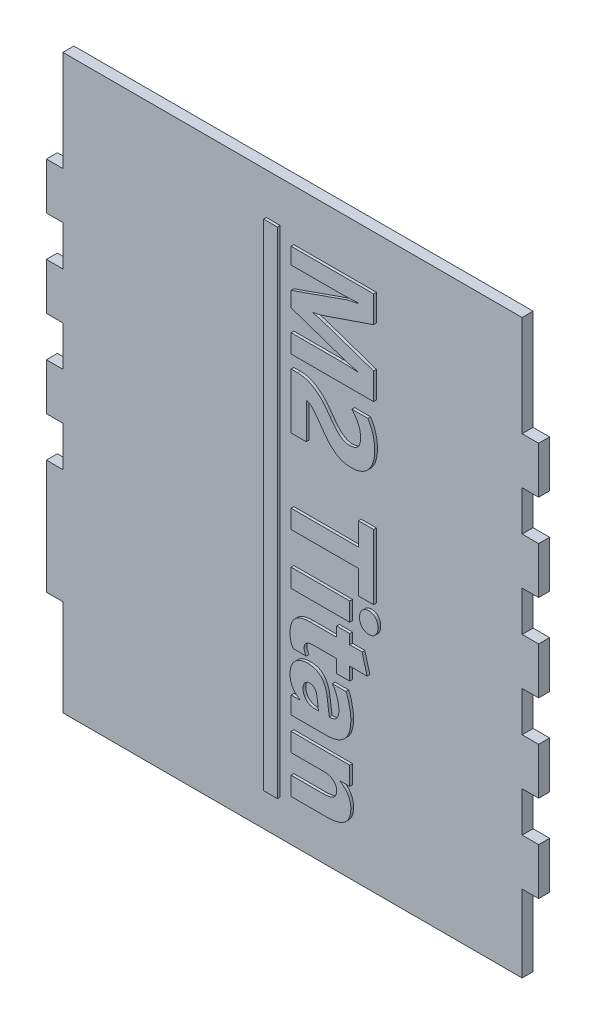
from build123d import *

# Parameters (mm, degrees)
SKETCH1_W           = 113.665
SKETCH1_H           = 132.08
BOSS_EXTRUDE1_DEPTH = 2.54
SKETCH2_W           = 3.81
SKETCH2_H           = 22.225
SKETCH2_H_2         = 23.241
SKETCH2_H_3         = 9.271
SKETCH2_H_4         = 17.78
CUT_EXTRUDE1_DEPTH  = 3.81
SKETCH5_W           = 3.175
SKETCH5_H           = 114.3
SKETCH5_W_2         = 13.535526316
SKETCH5_H_2         = 4.261184211
BOSS_EXTRUDE2_DEPTH = 0.635


with BuildPart() as part:
    # Sketch1 → Boss-Extrude1 (new body)
    with BuildSketch(Plane.XY):
        with Locations((56.8325, 66.04)):
            Rectangle(SKETCH1_W, SKETCH1_H)
    extrude(amount=BOSS_EXTRUDE1_DEPTH)

    # Sketch2 → Cut-Extrude1 (cut)
    with BuildSketch(Plane.XY.offset(2.54)):
        with Locations((1.905, 11.1125)):
            Rectangle(SKETCH2_W, SKETCH2_H)
        with Locations((1.905, 120.4595)):
            Rectangle(SKETCH2_W, SKETCH2_H_2)
        with Locations((1.905, 93.4085)):
            Rectangle(SKETCH2_W, SKETCH2_H_3)
        with Locations((1.905, 73.3425)):
            Rectangle(SKETCH2_W, SKETCH2_H_3)
        with Locations((1.905, 53.2765)):
            Rectangle(SKETCH2_W, SKETCH2_H_3)
        with Locations((111.76, 120.4595)):
            Rectangle(SKETCH2_W, SKETCH2_H_2)
        with Locations((111.76, 93.4085)):
            Rectangle(SKETCH2_W, SKETCH2_H_3)
        with Locations((111.76, 73.3425)):
            Rectangle(SKETCH2_W, SKETCH2_H_3)
        with Locations((111.76, 53.2765)):
            Rectangle(SKETCH2_W, SKETCH2_H_3)
        with Locations((111.76, 33.2105)):
            Rectangle(SKETCH2_W, SKETCH2_H_3)
        with Locations((111.76, 8.89)):
            Rectangle(SKETCH2_W, SKETCH2_H_4)
    extrude(amount=-CUT_EXTRUDE1_DEPTH, mode=Mode.SUBTRACT)

    # Sketch5 → Boss-Extrude2 (add)
    with BuildSketch(Plane.XY.offset(2.54)):
        with Locations((52.3875, 65.405)):
            Rectangle(SKETCH5_W, SKETCH5_H)
        with BuildLine():
            Line((57.15, 98.7425), (57.15, 103.003684211))
            Line((57.15, 103.003684211), (68.547101151, 103.003684211))
            add(Edge.make_bspline(
                [(68.547101151, 103.003684211), (68.863046339, 103.000629878), (69.5120088, 102.994356171), (70.508408278, 102.967962125), (71.552893128, 102.915680805), (72.26395596, 102.867686605), (72.628125, 102.843106497)],
                knots=[0, 0, 0, 0, 0.000947873, 0.001946964, 0.002990005, 0.004084988, 0.004084988, 0.004084988, 0.004084988], degree=3))
            Line((72.628125, 102.843106497), (72.628125, 102.948852796))
            add(Edge.make_bspline(
                [(72.628125, 102.948852796), (72.487117541, 102.976198315), (72.21540985, 103.028890475), (71.821986347, 103.106358345), (71.460684469, 103.18500854), (71.128571044, 103.258679244), (70.828787227, 103.333904656), (70.557686106, 103.402704312), (70.319131092, 103.473548316), (70.17106646, 103.521694876), (70.101963405, 103.544165296)],
                knots=[0, 0, 0, 0, 0.000430907, 0.000830316, 0.001202881, 0.001540181, 0.001850799, 0.002130083, 0.002379176, 0.002597168, 0.002597168, 0.002597168, 0.002597168], degree=3))
            Line((70.101963405, 103.544165296), (57.15, 107.985509868))
            Line((57.15, 107.985509868), (57.15, 111.475137747))
            Line((57.15, 111.475137747), (69.968801398, 115.994812911))
            add(Edge.make_bspline(
                [(69.968801398, 115.994812911), (70.019504819, 116.012485416), (70.137819051, 116.053723441), (70.344560255, 116.104300114), (70.601845366, 116.167536572), (70.907392822, 116.243813834), (71.266852338, 116.314240018), (71.674633282, 116.403054004), (72.13411484, 116.496211169), (72.458339275, 116.557848144), (72.628125, 116.590125411)],
                knots=[0, 0, 0, 0, 0.000161007, 0.000375703, 0.000637876, 0.000956105, 0.001320195, 0.001736528, 0.00220814, 0.002726618, 0.002726618, 0.002726618, 0.002726618], degree=3))
            Line((72.628125, 116.590125411), (72.628125, 116.707621299))
            add(Edge.make_bspline(
                [(72.628125, 116.707621299), (72.172575491, 116.681315442), (71.291789859, 116.630454185), (70.012144461, 116.581065874), (68.820129558, 116.547491312), (68.053638679, 116.541897461), (67.685464638, 116.539210526)],
                knots=[0, 0, 0, 0, 0.001368893, 0.002646696, 0.003841649, 0.004946173, 0.004946173, 0.004946173, 0.004946173], degree=3))
            Line((67.685464638, 116.539210526), (57.15, 116.539210526))
            Line((57.15, 116.539210526), (57.15, 120.299078947))
            Line((57.15, 120.299078947), (76.2, 120.299078947))
            Line((76.2, 120.299078947), (76.2, 114.134461349))
            Line((76.2, 114.134461349), (64.908645148, 110.261013569))
            add(Edge.make_bspline(
                [(64.908645148, 110.261013569), (64.683442113, 110.187053898), (64.234644325, 110.039662736), (63.553067513, 109.857982107), (62.871413996, 109.702674812), (62.414232426, 109.625691265), (62.186657072, 109.587370477)],
                knots=[0, 0, 0, 0, 0.000710977, 0.001416876, 0.002115261, 0.002807468, 0.002807468, 0.002807468, 0.002807468], degree=3))
            Line((62.186657072, 109.587370477), (62.186657072, 109.509039885))
            add(Edge.make_bspline(
                [(62.186657072, 109.509039885), (62.441483523, 109.450036023), (62.935388553, 109.335674644), (63.648968748, 109.152304128), (64.311084034, 108.961245176), (64.732758639, 108.823484725), (64.936060855, 108.757066201)],
                knots=[0, 0, 0, 0, 0.000784685, 0.001520878, 0.002210032, 0.002851626, 0.002851626, 0.002851626, 0.002851626], degree=3))
            Line((64.936060855, 108.757066201), (76.2, 104.883618421))
            Line((76.2, 104.883618421), (76.2, 98.7425))
            Line((76.2, 98.7425), (57.15, 98.7425))
        make_face()
        with BuildLine():
            Line((60.659210526, 91.222763158), (60.659210526, 82.951052632))
            Line((60.659210526, 82.951052632), (57.15, 82.951052632))
            Line((57.15, 82.951052632), (57.15, 95.734605263))
            Line((57.15, 95.734605263), (58.626531661, 95.734605263))
            add(Edge.make_bspline(
                [(58.626531661, 95.734605263), (58.861892718, 95.729064478), (59.321522061, 95.718244048), (59.99132946, 95.619819095), (60.627215256, 95.471158506), (61.222849985, 95.247935722), (61.781855966, 94.976879289), (62.317755731, 94.685968648), (62.819673151, 94.355723464), (63.289466648, 93.992402029), (63.735712991, 93.609775333), (64.155411445, 93.205675263), (64.547503775, 92.783062558), (65.021577135, 92.204147604), (65.569046885, 91.493069928), (65.979492703, 90.917168161), (66.17760074, 90.639200247)],
                knots=[0, 0, 0, 0, 0.000705671, 0.001378084, 0.002026881, 0.002661311, 0.003281472, 0.003889746, 0.004489371, 0.005081584, 0.005670367, 0.006252048, 0.00682851, 0.007398671, 0.008496173, 0.009520127, 0.009520127, 0.009520127, 0.009520127], degree=3))
            add(Edge.make_bspline(
                [(66.17760074, 90.639200247), (66.370124281, 90.372731172), (66.735064922, 89.86762206), (67.287113002, 89.168444547), (67.833665454, 88.578626313), (68.367322945, 88.079640608), (68.911594256, 87.693583523), (69.467478997, 87.411812645), (70.051761037, 87.243777965), (70.452081509, 87.222818694), (70.654194079, 87.212236842)],
                knots=[0, 0, 0, 0, 0.000986235, 0.001869471, 0.002670408, 0.003396753, 0.004057394, 0.004665176, 0.005259108, 0.005864741, 0.005864741, 0.005864741, 0.005864741], degree=3))
            add(Edge.make_bspline(
                [(70.654194079, 87.212236842), (70.852120603, 87.21942241), (71.226654642, 87.233019575), (71.750910931, 87.362899937), (72.198721721, 87.579804521), (72.505895062, 87.837974571), (72.703661213, 88.086009256), (72.838507344, 88.292956245), (72.947201076, 88.527147566), (73.036668494, 88.781830632), (73.107571489, 89.059585893), (73.158230215, 89.35947813), (73.183742641, 89.683132443), (73.189255662, 89.905467033), (73.192105263, 90.020388569)],
                knots=[0, 0, 0, 0, 0.000592963, 0.001122057, 0.001607233, 0.002074105, 0.002310821, 0.002557438, 0.002813214, 0.003083256, 0.003366332, 0.003672173, 0.003994496, 0.004339351, 0.004339351, 0.004339351, 0.004339351], degree=3))
            add(Edge.make_bspline(
                [(73.192105263, 90.020388569), (73.186054733, 90.224404484), (73.173928802, 90.633274903), (73.075994693, 91.242228233), (72.919225176, 91.844490506), (72.696921681, 92.439273248), (72.414104573, 93.028024111), (72.066589959, 93.608749049), (71.659021622, 94.183438752), (71.346562033, 94.546425696), (71.186842105, 94.731973684)],
                knots=[0, 0, 0, 0, 0.000611781, 0.001226078, 0.001845447, 0.002476203, 0.003127855, 0.003802226, 0.00450428, 0.005238418, 0.005238418, 0.005238418, 0.005238418], degree=3))
            Line((71.186842105, 94.731973684), (74.852713816, 94.731973684))
            add(Edge.make_bspline(
                [(74.852713816, 94.731973684), (74.981389983, 94.523683843), (75.237468921, 94.109165426), (75.56091837, 93.455622809), (75.837908598, 92.783540233), (76.058525966, 92.089642545), (76.237906742, 91.377343698), (76.361021605, 90.645260993), (76.438592194, 89.892831077), (76.446600665, 89.384798083), (76.450657895, 89.127419819)],
                knots=[0, 0, 0, 0, 0.000734148, 0.001461031, 0.002184699, 0.002912984, 0.003643457, 0.004386494, 0.005138243, 0.005910157, 0.005910157, 0.005910157, 0.005910157], degree=3))
            add(Edge.make_bspline(
                [(76.450657895, 89.127419819), (76.446229739, 88.89226763), (76.437573943, 88.432611317), (76.367680036, 87.761575045), (76.245333823, 87.129491885), (76.081664964, 86.535634315), (75.874860641, 85.981704783), (75.624718253, 85.470925998), (75.331424704, 85.005161301), (75.005082706, 84.57980529), (74.6315553, 84.205438786), (74.224918277, 83.87437183), (73.776095523, 83.595041867), (73.29504365, 83.359897958), (72.779251185, 83.174233849), (72.232249026, 83.047537199), (71.656623363, 82.966555668), (71.262841491, 82.956297375), (71.061513158, 82.951052632)],
                knots=[0, 0, 0, 0, 0.000705367, 0.001378794, 0.002020937, 0.002634784, 0.003224738, 0.003792243, 0.004337753, 0.004873617, 0.005397041, 0.005920627, 0.006443304, 0.006979297, 0.007524384, 0.008083914, 0.008661067, 0.009264836, 0.009264836, 0.009264836, 0.009264836], degree=3))
            add(Edge.make_bspline(
                [(71.061513158, 82.951052632), (70.849830202, 82.95685499), (70.435581034, 82.968209811), (69.83167666, 83.04102457), (69.263601146, 83.170718817), (68.73202531, 83.352463626), (68.232364421, 83.578736552), (67.756160799, 83.838512692), (67.302691406, 84.131100964), (66.873326074, 84.458867194), (66.467644451, 84.817399312), (66.073970837, 85.196351108), (65.701361372, 85.605745652), (65.227711877, 86.188710421), (64.661328759, 86.954841392), (64.226751839, 87.584413197), (64.007843339, 87.901546053)],
                knots=[0, 0, 0, 0, 0.00063507, 0.001242789, 0.001821389, 0.002379971, 0.002925172, 0.003464985, 0.004005991, 0.00454257, 0.005083803, 0.005629439, 0.006181113, 0.006743269, 0.007882198, 0.009038238, 0.009038238, 0.009038238, 0.009038238], degree=3))
            add(Edge.make_bspline(
                [(64.007843339, 87.901546053), (63.861157232, 88.114940483), (63.571409507, 88.536456549), (63.132716541, 89.14356881), (62.710302451, 89.714058531), (62.281283012, 90.207803782), (61.867587585, 90.628225568), (61.514865035, 90.905703716), (61.238345985, 91.071267293), (61.043019134, 91.158278232), (60.850312697, 91.2143565), (60.722229641, 91.219990923), (60.659210526, 91.222763158)],
                knots=[0, 0, 0, 0, 0.000776797, 0.0015344, 0.002247219, 0.002905254, 0.003495144, 0.004014524, 0.004246262, 0.004460206, 0.004654972, 0.004843617, 0.004843617, 0.004843617, 0.004843617], degree=3))
        make_face()
        Polygon((72.690789474, 58.135921053), (72.690789474, 63.650394737), (57.15, 63.650394737), (57.15, 67.911578947), (72.690789474, 67.911578947), (72.690789474, 73.175394737), (76.2, 73.175394737), (76.2, 58.135921053), align=None)
        with BuildLine():
            add(Edge.make_bspline(
                [(72.941447368, 54.000065789), (72.94835957, 54.166655713), (72.961772877, 54.489927806), (73.082789794, 54.949311021), (73.275659107, 55.365160478), (73.553285513, 55.717842985), (73.877732681, 56.014084389), (74.251244078, 56.225903585), (74.659981821, 56.357479492), (74.945718091, 56.37325859), (75.091622122, 56.381315789)],
                knots=[0, 0, 0, 0, 0.000498939, 0.000968204, 0.001414929, 0.00186458, 0.00230562, 0.002724853, 0.003143537, 0.003580402, 0.003580402, 0.003580402, 0.003580402], degree=3))
            add(Edge.make_bspline(
                [(75.091622122, 56.381315789), (75.241501063, 56.373603751), (75.531277028, 56.358693294), (75.942563772, 56.226325814), (76.312325857, 56.016936428), (76.622913314, 55.716815264), (76.884001964, 55.362293642), (77.068672435, 54.948250205), (77.186303406, 54.489594046), (77.197076156, 54.166620644), (77.202631579, 54.000065789)],
                knots=[0, 0, 0, 0, 0.000448558, 0.000867242, 0.001283077, 0.001712558, 0.002152833, 0.002596249, 0.003064549, 0.003563195, 0.003563195, 0.003563195, 0.003563195], degree=3))
            add(Edge.make_bspline(
                [(77.202631579, 54.000065789), (77.197316569, 53.830865262), (77.187087023, 53.505213115), (77.06787034, 53.043032088), (76.884732995, 52.627338162), (76.625441316, 52.271280016), (76.309390578, 51.980128873), (75.94363767, 51.768427152), (75.530398867, 51.642804861), (75.241333186, 51.627000885), (75.091622122, 51.618815789)],
                knots=[0, 0, 0, 0, 0.00050646, 0.00097476, 0.001421742, 0.001862017, 0.002286179, 0.002702014, 0.003119543, 0.003568101, 0.003568101, 0.003568101, 0.003568101], degree=3))
            add(Edge.make_bspline(
                [(75.091622122, 51.618815789), (74.940642491, 51.627127166), (74.647835463, 51.643246093), (74.228141735, 51.768261764), (73.85486076, 51.979956114), (73.530503233, 52.269651163), (73.267814497, 52.62726363), (73.078985902, 53.042032912), (72.962136944, 53.505504073), (72.948522839, 53.830934394), (72.941447368, 54.000065789)],
                knots=[0, 0, 0, 0, 0.000452457, 0.000877486, 0.001300126, 0.001730107, 0.002172692, 0.002621302, 0.003089601, 0.003596349, 0.003596349, 0.003596349, 0.003596349], degree=3))
        make_face()
        with Locations((63.917763158, 54.00006579)):
            Rectangle(SKETCH5_W_2, SKETCH5_H_2)
        with BuildLine():
            add(Edge.make_bspline(
                [(57.651315789, 40.088552632), (57.59046431, 40.169410623), (57.465943413, 40.334871016), (57.314835451, 40.616628503), (57.186089938, 40.926504087), (57.080861655, 41.264915682), (56.998192103, 41.632883111), (56.941424203, 42.031006632), (56.905524587, 42.458699766), (56.901443177, 42.753022739), (56.899342105, 42.904537418)],
                knots=[0, 0, 0, 0, 0.000303221, 0.000620484, 0.0009558, 0.001308831, 0.001682239, 0.002086021, 0.002514376, 0.002968845, 0.002968845, 0.002968845, 0.002968845], degree=3))
            add(Edge.make_bspline(
                [(56.899342105, 42.904537418), (56.903561841, 43.084804549), (56.91171309, 43.433025911), (56.961265964, 43.939007252), (57.050963445, 44.409544131), (57.176956281, 44.847316344), (57.334388867, 45.252908029), (57.537436416, 45.618531232), (57.769710982, 45.953115189), (58.039951644, 46.250226439), (58.346815238, 46.512815862), (58.688759887, 46.740116239), (59.067524477, 46.932488753), (59.481357958, 47.088806959), (59.931261156, 47.21070244), (60.41666028, 47.293006753), (60.937160481, 47.351864216), (61.296118271, 47.355666161), (61.481681743, 47.357631579)],
                knots=[0, 0, 0, 0, 0.000540836, 0.00104473, 0.001523269, 0.001975708, 0.002409896, 0.002825307, 0.003227338, 0.003629369, 0.004026564, 0.00443608, 0.004858213, 0.005298278, 0.005760976, 0.00625421, 0.006774091, 0.007330459, 0.007330459, 0.007330459, 0.007330459], degree=3))
            Line((61.481681743, 47.357631579), (67.677631579, 47.357631579))
            Line((67.677631579, 47.357631579), (67.677631579, 49.613552632))
            Line((67.677631579, 49.613552632), (70.685526316, 49.613552632))
            Line((70.685526316, 49.613552632), (70.685526316, 47.357631579))
            Line((70.685526316, 47.357631579), (73.536759868, 47.357631579))
            Line((73.536759868, 47.357631579), (74.696052632, 43.096447368))
            Line((74.696052632, 43.096447368), (70.685526316, 43.096447368))
            Line((70.685526316, 43.096447368), (70.685526316, 40.088552632))
            Line((70.685526316, 40.088552632), (67.677631579, 40.088552632))
            Line((67.677631579, 40.088552632), (67.677631579, 43.096447368))
            Line((67.677631579, 43.096447368), (62.253238076, 43.096447368))
            add(Edge.make_bspline(
                [(62.253238076, 43.096447368), (62.089848258, 43.090880135), (61.782060416, 43.080392781), (61.349299798, 43.011712945), (60.983740848, 42.877274723), (60.677743552, 42.696079601), (60.441304109, 42.455375347), (60.270053923, 42.161474546), (60.173032414, 41.813892712), (60.163094222, 41.565692669), (60.157894737, 41.435838816)],
                knots=[0, 0, 0, 0, 0.000490333, 0.000923672, 0.001307812, 0.001652399, 0.00198197, 0.002308431, 0.002662958, 0.003051959, 0.003051959, 0.003051959, 0.003051959], degree=3))
            add(Edge.make_bspline(
                [(60.157894737, 41.435838816), (60.164109976, 41.325504183), (60.1768309, 41.099678853), (60.279216314, 40.761769164), (60.435758832, 40.417980162), (60.582633737, 40.201447289), (60.659210526, 40.088552632)],
                knots=[0, 0, 0, 0, 0.000330477, 0.000676398, 0.001051425, 0.001459947, 0.001459947, 0.001459947, 0.001459947], degree=3))
            Line((60.659210526, 40.088552632), (57.651315789, 40.088552632))
        make_face()
        with BuildLine():
            Line((57.15, 26.553026316), (57.15, 30.563552632))
            Line((57.15, 30.563552632), (59.217927632, 30.563552632))
            Line((59.217927632, 30.563552632), (59.217927632, 30.614467516))
            add(Edge.make_bspline(
                [(59.217927632, 30.614467516), (59.033207836, 30.730011959), (58.673958437, 30.954726755), (58.201012403, 31.36041096), (57.794729835, 31.800279794), (57.466929396, 32.288587028), (57.210512086, 32.815810368), (57.030346387, 33.384429779), (56.916958117, 33.992521256), (56.905319253, 34.412982258), (56.899342105, 34.628910362)],
                knots=[0, 0, 0, 0, 0.00065284, 0.001269665, 0.001862965, 0.002444117, 0.003027417, 0.003615745, 0.004228779, 0.004875967, 0.004875967, 0.004875967, 0.004875967], degree=3))
            add(Edge.make_bspline(
                [(56.899342105, 34.628910362), (56.901423993, 34.78837797), (56.905481743, 35.099191871), (56.96378555, 35.550736942), (57.048140734, 35.97711593), (57.168922801, 36.377812052), (57.326881724, 36.750951932), (57.515112438, 37.100976033), (57.743888546, 37.420795757), (58.001761618, 37.717017159), (58.293214851, 37.9763386), (58.602311365, 38.212491663), (58.942387721, 38.403701445), (59.304365591, 38.558982868), (59.685813772, 38.687990903), (60.093802181, 38.77043225), (60.523043409, 38.828936093), (60.818270603, 38.833128272), (60.968616365, 38.835263158)],
                knots=[0, 0, 0, 0, 0.000478073, 0.0009318, 0.001363471, 0.001781, 0.002184707, 0.002577298, 0.002970671, 0.003361952, 0.003752919, 0.004139089, 0.004526746, 0.004919651, 0.005319693, 0.005732195, 0.006166489, 0.006617162, 0.006617162, 0.006617162, 0.006617162], degree=3))
            add(Edge.make_bspline(
                [(60.968616365, 38.835263158), (61.126751116, 38.831404753), (61.436159736, 38.823855344), (61.888195414, 38.767689385), (62.314635193, 38.67942217), (62.715651642, 38.553772148), (63.088968245, 38.387665844), (63.43908994, 38.188308926), (63.762263522, 37.951736666), (64.058961952, 37.678349913), (64.329093553, 37.368177654), (64.572667947, 37.021417001), (64.789066214, 36.63778866), (64.978219515, 36.218645097), (65.150372112, 35.766338159), (65.283679706, 35.273471775), (65.397888028, 34.746622495), (65.452500143, 34.381233938), (65.48045847, 34.194175576)],
                knots=[0, 0, 0, 0, 0.000474305, 0.000928031, 0.001364333, 0.001779282, 0.002186092, 0.002587837, 0.002985784, 0.003384925, 0.003795731, 0.004217336, 0.00465406, 0.00511498, 0.005595837, 0.006104232, 0.006645025, 0.007212287, 0.007212287, 0.007212287, 0.007212287], degree=3))
            Line((65.48045847, 34.194175576), (65.966108141, 30.536136924))
            add(Edge.make_bspline(
                [(65.966108141, 30.536136924), (66.139141926, 30.543039831), (66.467199942, 30.556127182), (66.925819205, 30.669808418), (67.3196572, 30.85931533), (67.639877801, 31.132958652), (67.891704715, 31.482528826), (68.059663597, 31.910421578), (68.161451877, 32.41000994), (68.172870073, 32.766703373), (68.178947368, 32.95655222)],
                knots=[0, 0, 0, 0, 0.000518463, 0.000982964, 0.001406837, 0.001818054, 0.00223328, 0.002686397, 0.003186442, 0.003755431, 0.003755431, 0.003755431, 0.003755431], degree=3))
            add(Edge.make_bspline(
                [(68.178947368, 32.95655222), (68.174394459, 33.157797446), (68.165290462, 33.56020739), (68.092790751, 34.158835038), (67.974360265, 34.750494078), (67.81055395, 35.333634994), (67.596440335, 35.909032721), (67.337428772, 36.477048029), (67.032420862, 37.0394819), (66.79519069, 37.399548793), (66.675, 37.581973684)],
                knots=[0, 0, 0, 0, 0.000603603, 0.001206965, 0.001806079, 0.002412382, 0.003022054, 0.003646013, 0.004283974, 0.004939113, 0.004939113, 0.004939113, 0.004939113], degree=3))
            Line((66.675, 37.581973684), (69.804307155, 37.581973684))
            add(Edge.make_bspline(
                [(69.804307155, 37.581973684), (69.878557366, 37.422416013), (70.036659912, 37.082666485), (70.235941467, 36.51806965), (70.428599906, 35.875436822), (70.595100053, 35.169357884), (70.750371608, 34.443456762), (70.852220121, 33.730080734), (70.926216273, 33.0507981), (70.932919301, 32.608168106), (70.936184211, 32.392571957)],
                knots=[0, 0, 0, 0, 0.000527701, 0.001123644, 0.001794012, 0.002539697, 0.003299352, 0.004019961, 0.004700785, 0.005347309, 0.005347309, 0.005347309, 0.005347309], degree=3))
            add(Edge.make_bspline(
                [(70.936184211, 32.392571957), (70.931669938, 32.156113274), (70.922946538, 31.699179432), (70.855973885, 31.035139309), (70.744267072, 30.417948127), (70.587204129, 29.84497998), (70.387929822, 29.316519836), (70.143123584, 28.831913089), (69.844517982, 28.399174618), (69.510113489, 28.004635594), (69.125265581, 27.659708258), (68.692816802, 27.364785001), (68.218824256, 27.112388068), (67.700128141, 26.905208218), (67.136964538, 26.745242628), (66.529948503, 26.632577943), (65.877497228, 26.566490208), (65.42708901, 26.557610658), (65.194551809, 26.553026316)],
                knots=[0, 0, 0, 0, 0.000709281, 0.001370618, 0.001999767, 0.002588876, 0.003150417, 0.003691664, 0.004213092, 0.004724135, 0.005239988, 0.005758185, 0.006290833, 0.006847931, 0.00743056, 0.008044307, 0.008697851, 0.00939539, 0.00939539, 0.00939539, 0.00939539], degree=3))
            Line((65.194551809, 26.553026316), (57.15, 26.553026316))
        make_face()
        with BuildLine():
            Line((62.601809211, 30.536136924), (63.459529194, 30.536136924))
            Line((63.459529194, 30.536136924), (63.161872944, 33.019216694))
            add(Edge.make_bspline(
                [(63.161872944, 33.019216694), (63.138283386, 33.180556511), (63.093633681, 33.48593634), (62.972093752, 33.907054937), (62.816925161, 34.266924952), (62.621023931, 34.563742744), (62.380039962, 34.794541497), (62.098353956, 34.958333957), (61.778325279, 35.060177668), (61.551649426, 35.070215274), (61.434683388, 35.075394737)],
                knots=[0, 0, 0, 0, 0.000488704, 0.000925006, 0.001310739, 0.001660519, 0.001984645, 0.002302367, 0.002630632, 0.002980609, 0.002980609, 0.002980609, 0.002980609], degree=3))
            add(Edge.make_bspline(
                [(61.434683388, 35.075394737), (61.326888783, 35.069830042), (61.117311101, 35.059010987), (60.819242544, 34.960987852), (60.554194441, 34.798852925), (60.32229079, 34.57803171), (60.135042477, 34.302854602), (59.998629502, 33.979850333), (59.922686851, 33.612805943), (59.912525351, 33.353772523), (59.907236842, 33.218959704)],
                knots=[0, 0, 0, 0, 0.00032268, 0.000627365, 0.000929624, 0.001248214, 0.001580634, 0.00192108, 0.002293645, 0.002697978, 0.002697978, 0.002697978, 0.002697978], degree=3))
            add(Edge.make_bspline(
                [(59.907236842, 33.218959704), (59.915301949, 33.029960052), (59.930964763, 32.66291389), (60.080111538, 32.141146983), (60.324677922, 31.674780769), (60.659129359, 31.272155343), (61.064873596, 30.940542878), (61.534214882, 30.708228407), (62.051082332, 30.559795664), (62.414058429, 30.544202532), (62.601809211, 30.536136924)],
                knots=[0, 0, 0, 0, 0.000565935, 0.001099073, 0.001612377, 0.002135406, 0.002658992, 0.003172192, 0.003696729, 0.004258761, 0.004258761, 0.004258761, 0.004258761], degree=3))
        make_face(mode=Mode.SUBTRACT)
        with BuildLine():
            Line((57.15, 10.260263158), (57.15, 14.521447368))
            Line((57.15, 14.521447368), (64.571823602, 14.521447368))
            add(Edge.make_bspline(
                [(64.571823602, 14.521447368), (64.6972303, 14.522352658), (64.940535268, 14.524109034), (65.291753206, 14.554558975), (65.62063981, 14.590619439), (65.923966011, 14.649937875), (66.205101688, 14.72281822), (66.460154428, 14.817605228), (66.692587801, 14.926952526), (66.900961367, 15.051514511), (67.085102869, 15.193825133), (67.240985204, 15.357238697), (67.381300881, 15.530708573), (67.485484385, 15.728187501), (67.574012017, 15.936981164), (67.636216267, 16.16465584), (67.671133657, 16.409421988), (67.675427594, 16.577512064), (67.677631579, 16.663789062)],
                knots=[0, 0, 0, 0, 0.000376068, 0.000729621, 0.001057043, 0.00136813, 0.001655989, 0.001927362, 0.002183139, 0.002425616, 0.002654389, 0.002878728, 0.003102005, 0.003321121, 0.003545869, 0.003781513, 0.004026883, 0.004285641, 0.004285641, 0.004285641, 0.004285641], degree=3))
            add(Edge.make_bspline(
                [(67.677631579, 16.663789062), (67.668293774, 16.829476434), (67.650004133, 17.15400263), (67.491877223, 17.616986959), (67.222605224, 18.026707955), (66.859453603, 18.380044517), (66.422733178, 18.674293979), (65.91790425, 18.882725189), (65.360082036, 19.009860032), (64.969398984, 19.025310728), (64.767650082, 19.033289474)],
                knots=[0, 0, 0, 0, 0.000496102, 0.000971699, 0.001447521, 0.001954329, 0.002482248, 0.00301761, 0.003583884, 0.004188567, 0.004188567, 0.004188567, 0.004188567], degree=3))
            Line((64.767650082, 19.033289474), (57.15, 19.033289474))
            Line((57.15, 19.033289474), (57.15, 23.294473684))
            Line((57.15, 23.294473684), (70.685526316, 23.294473684))
            Line((70.685526316, 23.294473684), (70.685526316, 19.033289474))
            Line((70.685526316, 19.033289474), (68.402189556, 19.033289474))
            Line((68.402189556, 19.033289474), (68.402189556, 18.982374589))
            add(Edge.make_bspline(
                [(68.402189556, 18.982374589), (68.604135368, 18.85814657), (68.996516932, 18.616771007), (69.513454294, 18.17964312), (69.953959617, 17.703437837), (70.313145645, 17.182063511), (70.595001278, 16.619508774), (70.795654378, 16.014461368), (70.914748839, 15.366880677), (70.928934179, 14.921437619), (70.936184211, 14.693774671)],
                knots=[0, 0, 0, 0, 0.000710448, 0.001380404, 0.002023502, 0.002651431, 0.003273222, 0.003904865, 0.004557834, 0.005240435, 0.005240435, 0.005240435, 0.005240435], degree=3))
            add(Edge.make_bspline(
                [(70.936184211, 14.693774671), (70.931198719, 14.514763718), (70.921523496, 14.167361486), (70.860297488, 13.661684091), (70.749989408, 13.192500587), (70.602025046, 12.754750615), (70.405038697, 12.353839888), (70.164823396, 11.986314627), (69.880305128, 11.654780262), (69.552516902, 11.358741546), (69.179936298, 11.100220217), (68.768057091, 10.870810747), (68.30880076, 10.685474696), (67.809089484, 10.527315409), (67.264855036, 10.408076841), (66.677067642, 10.323920706), (66.048186069, 10.26642663), (65.613756598, 10.262356149), (65.390378289, 10.260263158)],
                knots=[0, 0, 0, 0, 0.000537079, 0.001042296, 0.001524904, 0.001980705, 0.002425606, 0.002861204, 0.003294508, 0.003732634, 0.004182473, 0.004652277, 0.005143953, 0.00566544, 0.006223212, 0.006813102, 0.007446043, 0.008115953, 0.008115953, 0.008115953, 0.008115953], degree=3))
            Line((65.390378289, 10.260263158), (57.15, 10.260263158))
        make_face()
    extrude(amount=BOSS_EXTRUDE2_DEPTH)


solid = part.part
